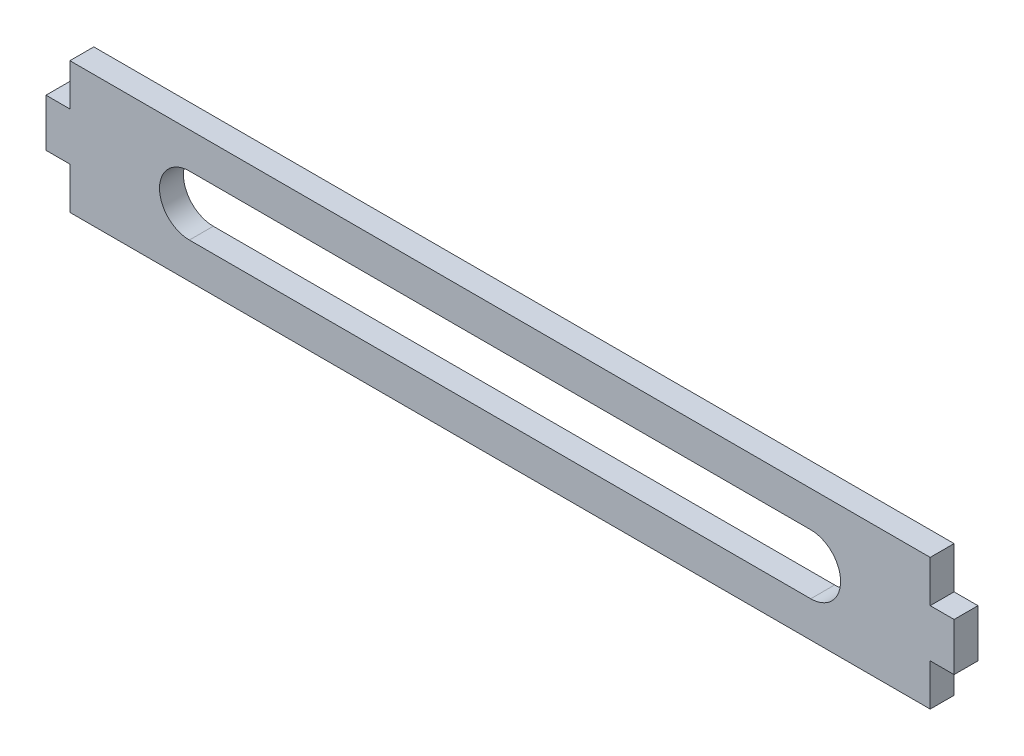
from build123d import *

# Parameters (mm, degrees)
BOSS_EXTRUDE1_DEPTH = 3.175
CUT_EXTRUDE2_DEPTH  = 4.175


with BuildPart() as part:
    # Sketch1 → Boss-Extrude1 (new body)
    with BuildSketch(Plane.XY):
        Polygon((0, 0), (-114.3, 0), (-114.3, 5.555107), (-117.475, 5.555107), (-117.475, 11.905107), (-114.3, 11.905107), (-114.3, 17.460214), (0, 17.460214), (0, 11.905107), (3.175, 11.905107), (3.175, 5.555107), (0, 5.555107), align=None)
    extrude(amount=BOSS_EXTRUDE1_DEPTH)

    # Sketch3 → Cut-Extrude2 (cut, through all)
    with BuildSketch(Plane.XY.offset(3.175)):
        with BuildLine():
            Line((-15.875, 4.761357), (-98.425, 4.761357))
            ThreePointArc((-98.425, 4.761357), (-102.39375, 8.730107), (-98.425, 12.698857))
            Line((-98.425, 12.698857), (-15.875, 12.698857))
            ThreePointArc((-15.875, 12.698857), (-11.90625, 8.730107), (-15.875, 4.761357))
        make_face()
    extrude(amount=-CUT_EXTRUDE2_DEPTH, mode=Mode.SUBTRACT)


solid = part.part
